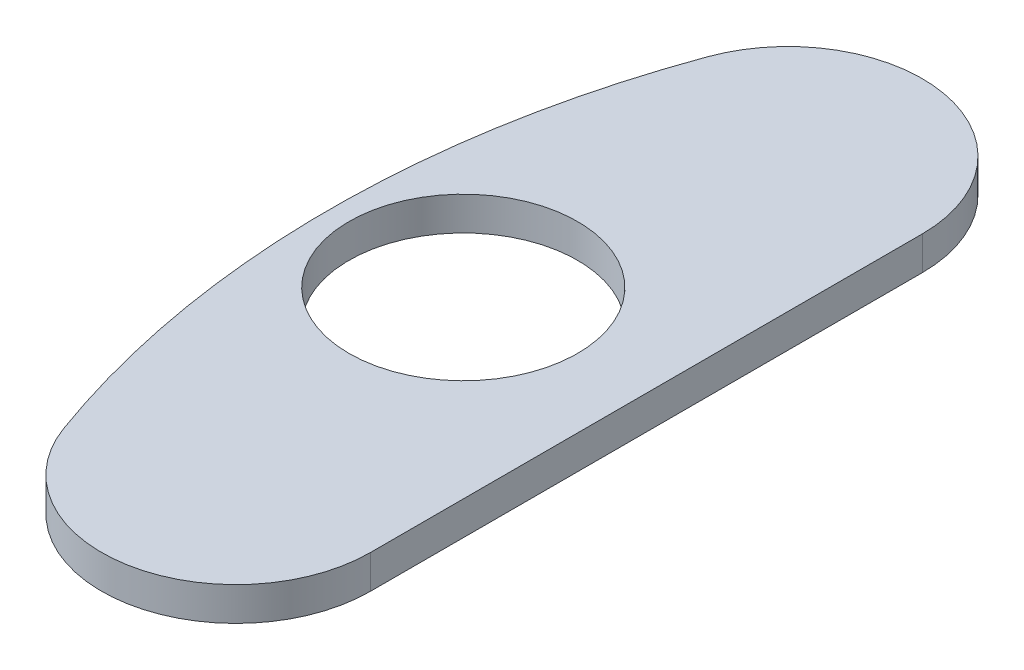
from build123d import *

# Parameters (mm, degrees)
SKETCH1_R           = 10.795
BOSS_EXTRUDE2_DEPTH = 3.175


with BuildPart() as part:
    # Sketch1 → Boss-Extrude2 (new body)
    with BuildSketch(Plane(origin=(0, 0, 0), x_dir=(1, 0, 0), z_dir=(0, 1, 0))):
        with BuildLine():
            Line((-58.904577704, 26.061934921), (-58.904577704, -26.061934921))
            ThreePointArc((-58.904577704, -26.061934921), (-69.399245848, -38.568993385), (-83.538673988, -30.405590742))
            ThreePointArc((-83.538673988, -30.405590742), (-88.9, 0), (-83.538673988, 30.405590742))
            ThreePointArc((-83.538673988, 30.405590742), (-69.399245848, 38.568993385), (-58.904577704, 26.061934921))
        make_face()
        with Locations((-76.2, 0)):
            Circle(SKETCH1_R, mode=Mode.SUBTRACT)
    extrude(amount=BOSS_EXTRUDE2_DEPTH)


solid = part.part
